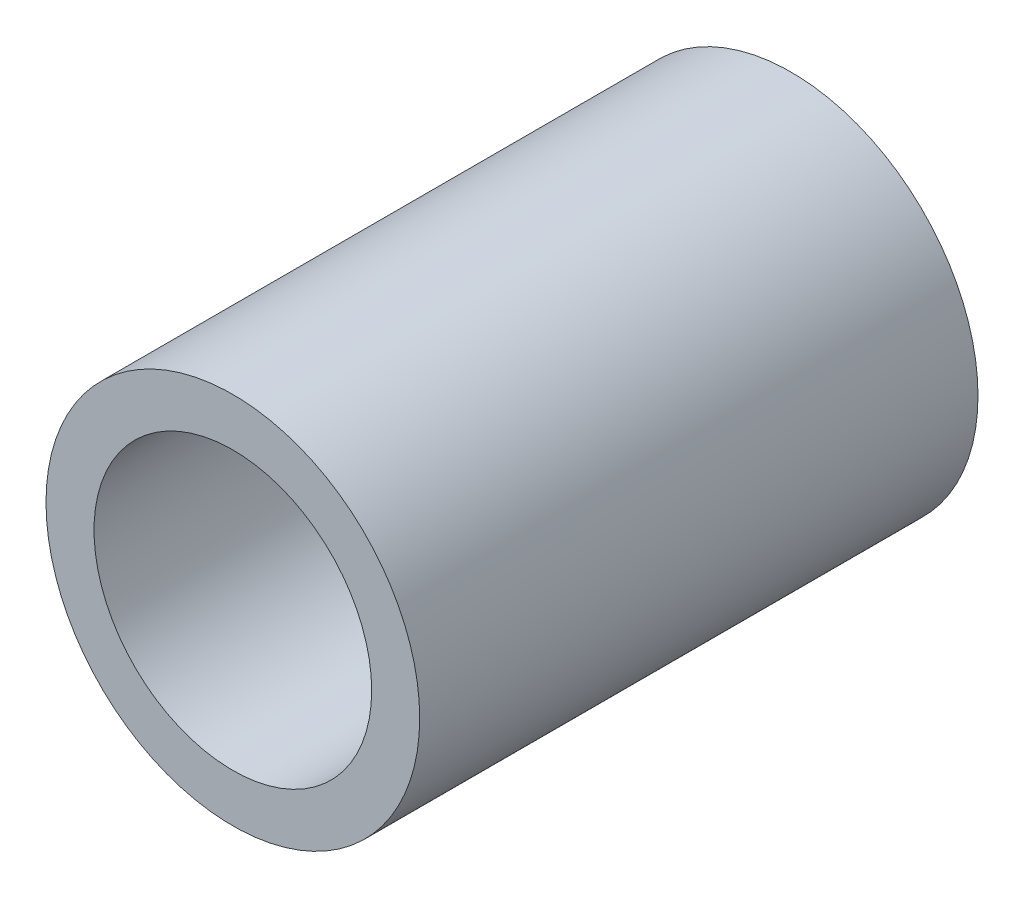
from build123d import *

# Parameters (mm, degrees)
SKETCH1_R      = 3.1877
SKETCH1_R_2    = 2.36855
EXTRUDE1_DEPTH = 4.7625


with BuildPart() as part:
    # Sketch1 → Extrude1 (new body, symmetric)
    with BuildSketch(Plane.XY):
        Circle(SKETCH1_R)
        Circle(SKETCH1_R_2, mode=Mode.SUBTRACT)
    extrude(amount=EXTRUDE1_DEPTH, both=True)


solid = part.part
